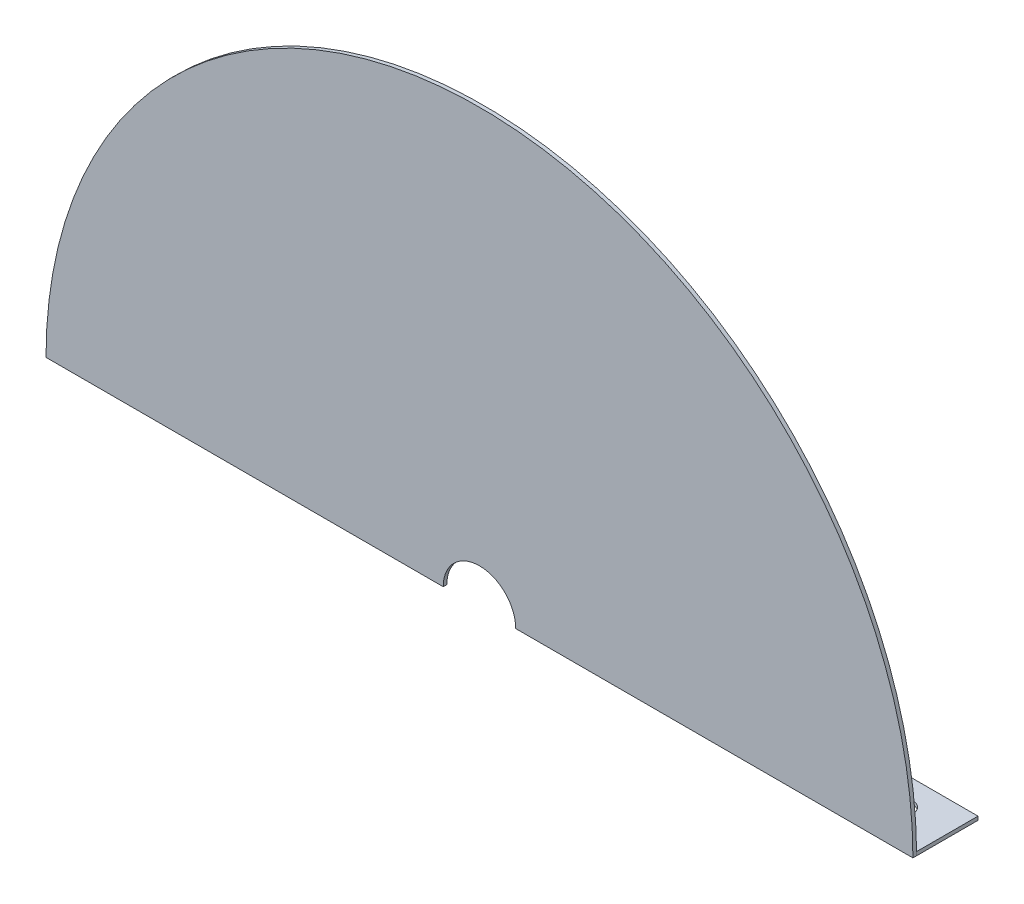
from build123d import *

# Parameters (mm, degrees)
OUTER_CASING_DEPTH  = 1.51892
SKETCH1_R           = 15
INNER_CUTOUT_DEPTH  = 20
SKETCH4_W           = 76.2
SKETCH4_H           = 1.51892
BOSS_EXTRUDE1_DEPTH = 25.4
SKETCH5_R           = 4.7625
CUT_EXTRUDE1_DEPTH  = 2.51892


with BuildPart() as part:
    # Plate shape → Outer casing (new body)
    with BuildSketch(Plane.XY):
        with BuildLine():
            Line((0, 179.31892), (-179.31892, 179.31892))
            ThreePointArc((-179.31892, 179.31892), (0, 358.63784), (179.31892, 179.31892))
            Line((179.31892, 179.31892), (0, 179.31892))
        make_face()
    extrude(amount=OUTER_CASING_DEPTH)

    # Sketch1 → Inner Cutout (cut)
    with BuildSketch(Plane.XY.offset(1.51892)):
        with Locations((0, 179.31892)):
            Circle(SKETCH1_R)
    extrude(amount=-INNER_CUTOUT_DEPTH, mode=Mode.SUBTRACT)

    # Sketch4 → Boss-Extrude1 (add)
    with BuildSketch(Plane(origin=(0, 0, 0), x_dir=(-1, 0, 0), z_dir=(0, 0, -1))):
        with Locations((-141.21892, 180.07838)):
            Rectangle(SKETCH4_W, SKETCH4_H)
        with Locations((141.21892, 180.07838)):
            Rectangle(SKETCH4_W, SKETCH4_H)
    extrude(amount=BOSS_EXTRUDE1_DEPTH)

    # Sketch5 → Cut-Extrude1 (cut, through all)
    with BuildSketch(Plane(origin=(0, 180.83784, 0), x_dir=(1, 0, 0), z_dir=(0, 1, 0))):
        with Locations((160.26892, 12.7)):
            Circle(SKETCH5_R)
        with Locations((122.16892, 12.7)):
            Circle(SKETCH5_R)
        with Locations((-160.26892, 12.7)):
            Circle(SKETCH5_R)
        with Locations((-122.16892, 12.7)):
            Circle(SKETCH5_R)
    extrude(amount=-CUT_EXTRUDE1_DEPTH, mode=Mode.SUBTRACT)


solid = part.part
